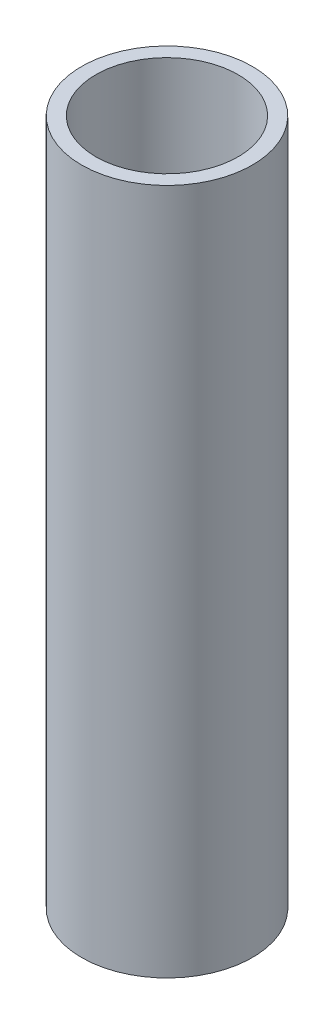
from build123d import *

# Parameters (mm, degrees)
SKETCH1_R           = 1.95
SKETCH1_R_2         = 1.625
BOSS_EXTRUDE1_DEPTH = 7.834


with BuildPart() as part:
    # Sketch1 → Boss-Extrude1 (new body, symmetric)
    with BuildSketch(Plane(origin=(0, 0, 0), x_dir=(1, 0, 0), z_dir=(0, 1, 0))):
        Circle(SKETCH1_R)
        Circle(SKETCH1_R_2, mode=Mode.SUBTRACT)
    extrude(amount=BOSS_EXTRUDE1_DEPTH, both=True)


solid = part.part
